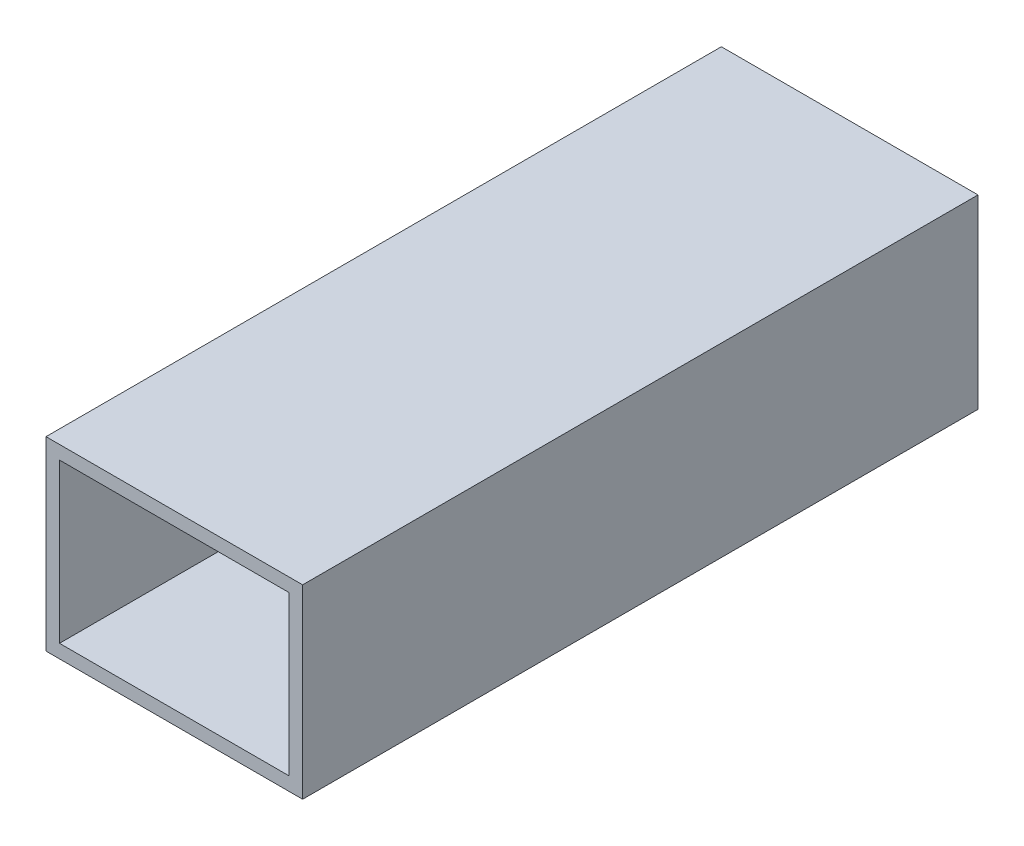
from build123d import *

# Parameters (mm, degrees)
SKETCH1_W           = 38
SKETCH1_H           = 27.5
SKETCH1_W_2         = 34
SKETCH1_H_2         = 23.5
BOSS_EXTRUDE1_DEPTH = 100


with BuildPart() as part:
    # Sketch1 → Boss-Extrude1 (new body)
    with BuildSketch(Plane.XY):
        with Locations((1.874666667, 0.856666667)):
            Rectangle(SKETCH1_W, SKETCH1_H)
        with Locations((1.874666667, 0.856666667)):
            Rectangle(SKETCH1_W_2, SKETCH1_H_2, mode=Mode.SUBTRACT)
    extrude(amount=BOSS_EXTRUDE1_DEPTH)


solid = part.part
